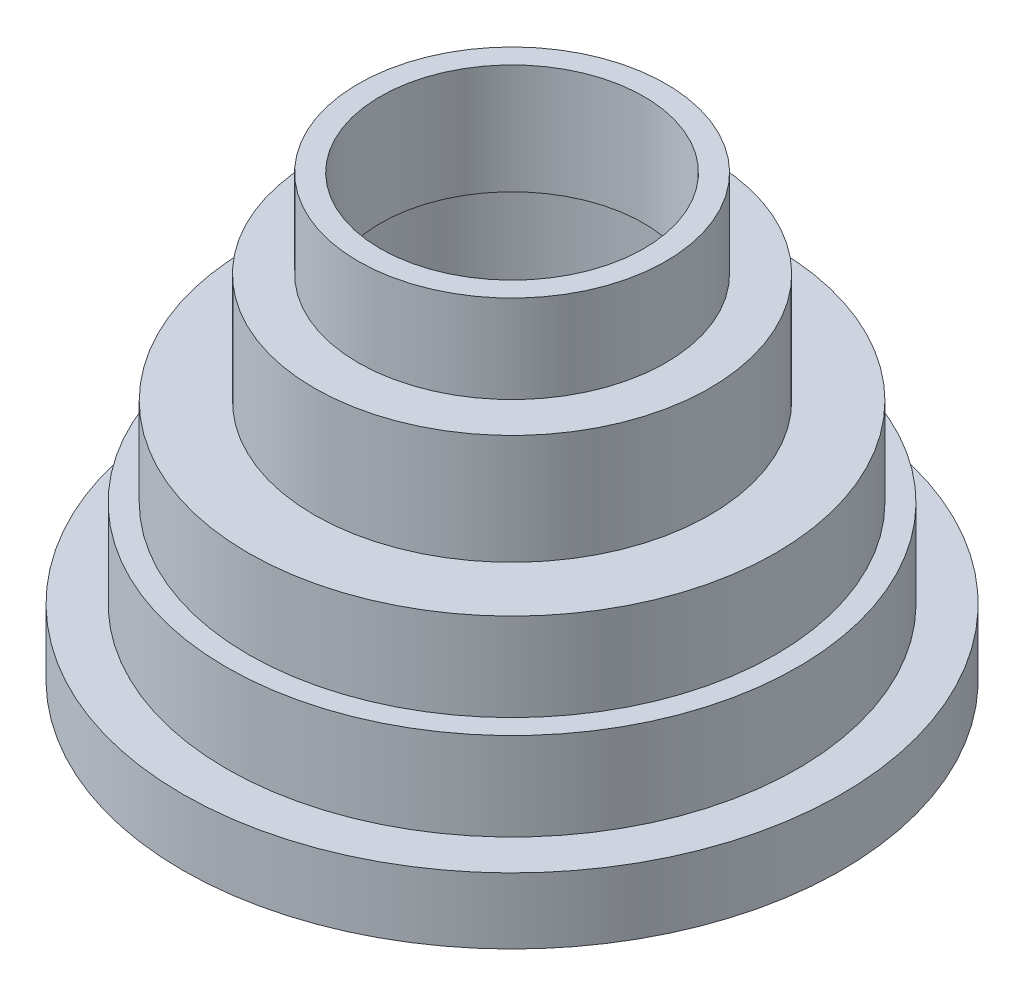
from build123d import *


with BuildPart() as part:
    # Sketch1 → Revolve-Thin1 (revolve)
    with BuildSketch(Plane.XY):
        Polygon((-75, -52.234042553), (-75, -37.234042553), (-65, -37.234042553), (-65, -17.234042553), (-60, -17.234042553), (-60, 2.765957447), (-45, 2.765957447), (-45, 27.765957447), (-35, 27.765957447), (-35, 47.765957447), (-30, 47.765957447), (-30, 22.765957447), (-40, 22.765957447), (-40, -2.234042553), (-55, -2.234042553), (-55, -22.234042553), (-60, -22.234042553), (-60, -42.234042553), (-70, -42.234042553), (-70, -52.234042553), align=None)
    revolve(axis=Axis((0, 50, 0), (0, -1, 0)))


solid = part.part
